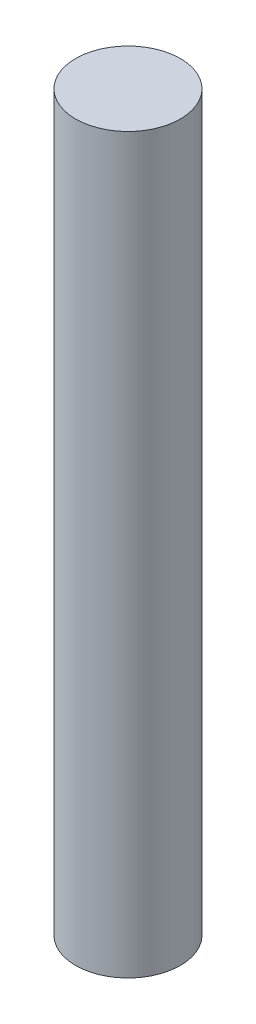
from build123d import *

# Parameters (mm, degrees)
SKETCH1_R           = 2.5
BOSS_EXTRUDE1_DEPTH = 35


with BuildPart() as part:
    # Sketch1 → Boss-Extrude1 (new body)
    with BuildSketch(Plane(origin=(0, 0, 0), x_dir=(1, 0, 0), z_dir=(0, 1, 0))):
        Circle(SKETCH1_R)
    extrude(amount=BOSS_EXTRUDE1_DEPTH)


solid = part.part
